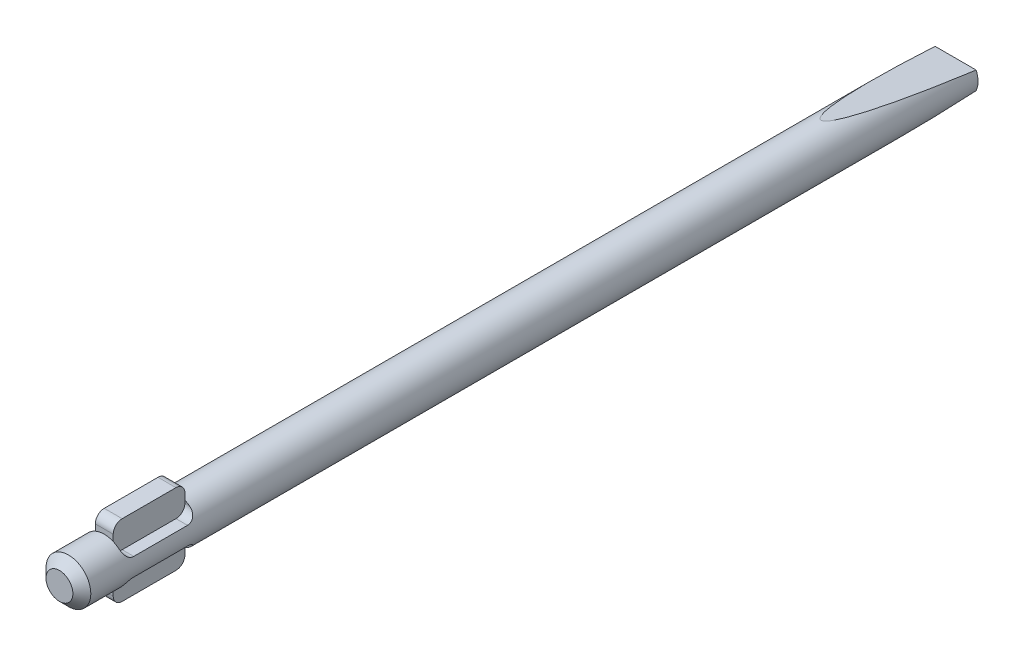
from build123d import *

# Parameters (mm, degrees)
SKETCH1_R           = 2.5
BOSS_EXTRUDE1_DEPTH = 100
CUT_EXTRUDE1_DEPTH  = 5
BOSS_EXTRUDE2_DEPTH = 1
CUT_EXTRUDE2_DEPTH  = 6
CHAMFER1_SIZE       = 1


with BuildPart() as part:
    # Sketch1 → Boss-Extrude1 (new body)
    with BuildSketch(Plane.XY):
        Circle(SKETCH1_R)
    extrude(amount=BOSS_EXTRUDE1_DEPTH)

    # Sketch2 → Cut-Extrude1 (cut, symmetric)
    with BuildSketch(Plane(origin=(0, 0, 0), x_dir=(0, 0, -1), z_dir=(1, 0, 0))):
        with BuildLine():
            Line((-94, 4), (-88, 4))
            ThreePointArc((-88, 4), (-87.292893219, 3.707106781), (-87, 3))
            Line((-87, 3), (-87, 2))
            ThreePointArc((-87, 2), (-87.292893219, 1.292893219), (-88, 1))
            Line((-88, 1), (-94, 1))
            ThreePointArc((-94, 1), (-94.707106781, 1.292893219), (-95, 2))
            Line((-95, 2), (-95, 3))
            ThreePointArc((-95, 3), (-94.707106781, 3.707106781), (-94, 4))
        make_face()
        with BuildLine():
            Line((-87, -3), (-87, -2))
            ThreePointArc((-87, -2), (-87.292893219, -1.292893219), (-88, -1))
            Line((-88, -1), (-94, -1))
            ThreePointArc((-94, -1), (-94.707106781, -1.292893219), (-95, -2))
            Line((-95, -2), (-95, -3))
            ThreePointArc((-95, -3), (-94.707106781, -3.707106781), (-94, -4))
            Line((-94, -4), (-88, -4))
            ThreePointArc((-88, -4), (-87.292893219, -3.707106781), (-87, -3))
        make_face()
    extrude(amount=CUT_EXTRUDE1_DEPTH, both=True, mode=Mode.SUBTRACT)

    # Sketch2_2 → Boss-Extrude2 (add, symmetric)
    with BuildSketch(Plane(origin=(0, 0, 0), x_dir=(0, 0, -1), z_dir=(1, 0, 0))):
        with BuildLine():
            Line((-94, 4), (-88, 4))
            ThreePointArc((-88, 4), (-87.292893219, 3.707106781), (-87, 3))
            Line((-87, 3), (-87, 2))
            ThreePointArc((-87, 2), (-87.292893219, 1.292893219), (-88, 1))
            Line((-88, 1), (-94, 1))
            ThreePointArc((-94, 1), (-94.707106781, 1.292893219), (-95, 2))
            Line((-95, 2), (-95, 3))
            ThreePointArc((-95, 3), (-94.707106781, 3.707106781), (-94, 4))
        make_face()
        with BuildLine():
            Line((-87, -3), (-87, -2))
            ThreePointArc((-87, -2), (-87.292893219, -1.292893219), (-88, -1))
            Line((-88, -1), (-94, -1))
            ThreePointArc((-94, -1), (-94.707106781, -1.292893219), (-95, -2))
            Line((-95, -2), (-95, -3))
            ThreePointArc((-95, -3), (-94.707106781, -3.707106781), (-94, -4))
            Line((-94, -4), (-88, -4))
            ThreePointArc((-88, -4), (-87.292893219, -3.707106781), (-87, -3))
        make_face()
    extrude(amount=BOSS_EXTRUDE2_DEPTH, both=True)

    # Sketch4 → Cut-Extrude2 (cut, symmetric)
    with BuildSketch(Plane(origin=(0, 0, 0), x_dir=(0, 0, -1), z_dir=(1, 0, 0))):
        Polygon((0, -2.5), (0, -1), (-15, -2.5), align=None)
        Polygon((-15, 2.5), (0, 1), (0, 2.5), align=None)
    extrude(amount=CUT_EXTRUDE2_DEPTH, both=True, mode=Mode.SUBTRACT)

    # Chamfer1
    chamfer1_edges = [part.edges().sort_by_distance(p)[0] for p in [
        (-2.5, 0, 100),
    ]]
    chamfer(chamfer1_edges, length=CHAMFER1_SIZE)


solid = part.part
